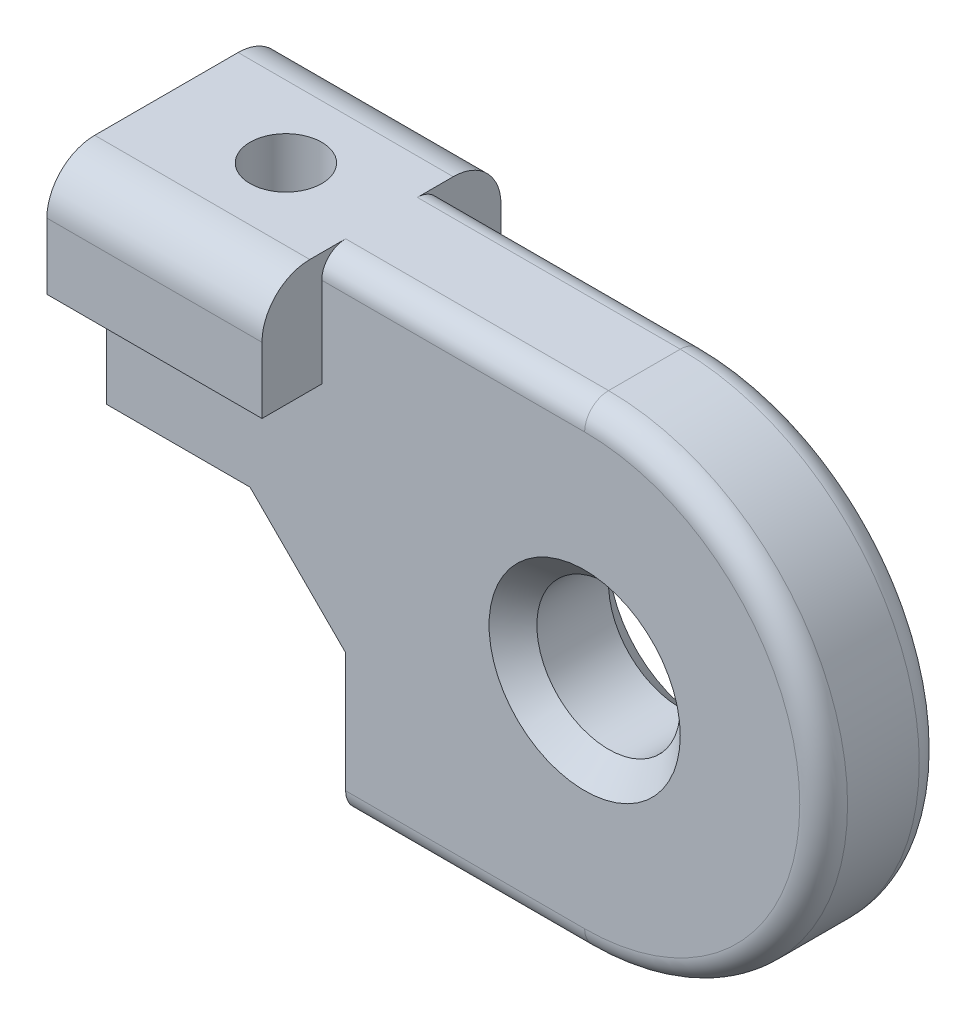
from build123d import *

# Parameters (mm, degrees)
SKETCH1_R           = 3
BOSS_EXTRUDE1_DEPTH = 2.5
SKETCH2_W           = 9
SKETCH2_H           = 4.761904762
BOSS_EXTRUDE2_DEPTH = 5
FILLET1_R           = 2
CHAMFER1_SIZE       = 1
FILLET2_R           = 1
SKETCH3_R           = 1.5
CUT_EXTRUDE1_DEPTH  = 20


with BuildPart() as part:
    # Sketch1 → Boss-Extrude1 (new body, symmetric)
    with BuildSketch(Plane.XY):
        with BuildLine():
            Line((0, 10), (-20, 10))
            Line((-20, 10), (-20, 0))
            Line((-20, 0), (-14, 0))
            Line((-14, 0), (-10, -4))
            Line((-10, -4), (-10, -10))
            Line((-10, -10), (0, -10))
            ThreePointArc((0, -10), (10, 0), (0, 10))
        make_face()
        Circle(SKETCH1_R, mode=Mode.SUBTRACT)
    extrude(amount=BOSS_EXTRUDE1_DEPTH, both=True)

    # Sketch2 → Boss-Extrude2 (add, symmetric)
    with BuildSketch(Plane.XY):
        with Locations((-15.5, 7.619047619)):
            Rectangle(SKETCH2_W, SKETCH2_H)
    extrude(amount=BOSS_EXTRUDE2_DEPTH, both=True)

    # Fillet1
    fillet1_edges = [part.edges().sort_by_distance(p)[0] for p in [
        (-15.5, 10, -5),
        (-15.5, 10, 5),
    ]]
    fillet(fillet1_edges, radius=FILLET1_R)

    # Chamfer1
    chamfer1_edges = [part.edges().sort_by_distance(p)[0] for p in [
        (-3, 0, -2.5),
        (-3, 0, 2.5),
    ]]
    chamfer(chamfer1_edges, length=CHAMFER1_SIZE)

    # Fillet2
    fillet2_edges = [part.edges().sort_by_distance(p)[0] for p in [
        (-5, -10, 2.5),
        (10, 0, 2.5),
        (-5.5, 10, 2.5),
        (-5.5, 10, -2.5),
        (10, 0, -2.5),
        (-5, -10, -2.5),
    ]]
    fillet(fillet2_edges, radius=FILLET2_R)

    # Sketch3 → Cut-Extrude1 (cut)
    with BuildSketch(Plane(origin=(0, 10, 0), x_dir=(1, 0, 0), z_dir=(0, 1, 0))):
        with Locations((-15, 0)):
            Circle(SKETCH3_R)
    extrude(amount=-CUT_EXTRUDE1_DEPTH, mode=Mode.SUBTRACT)


solid = part.part
